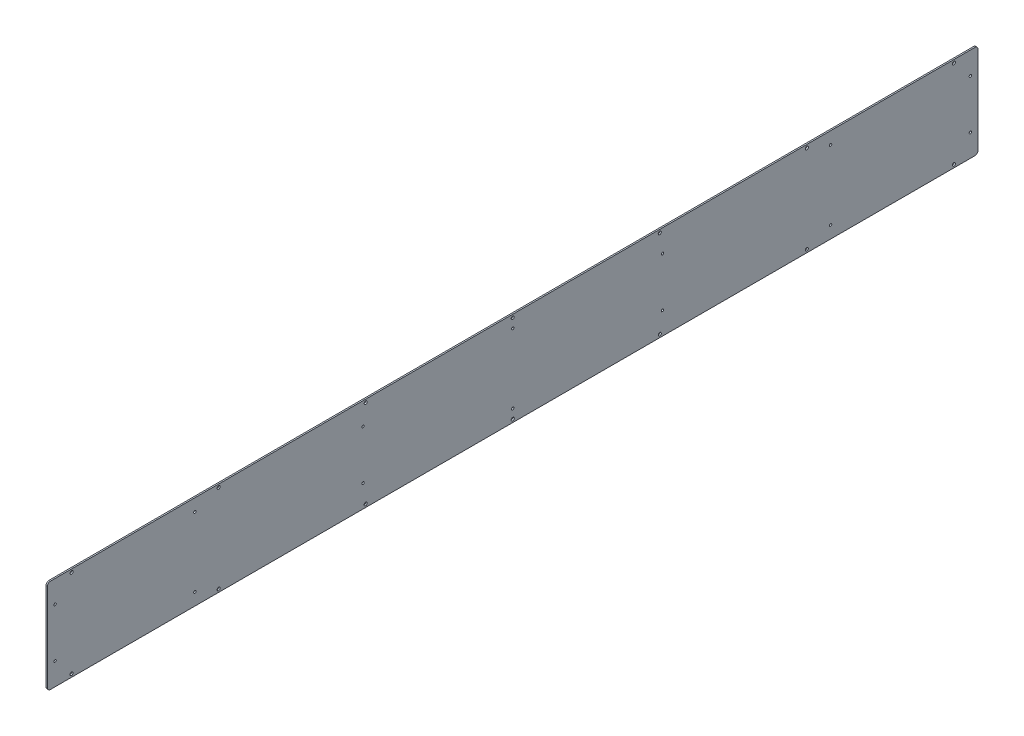
from build123d import *

# Parameters (mm, degrees)
SKETCH1_W                   = 1928.8125
SKETCH1_H                   = 194.564
BOSS_EXTRUDE1_DEPTH         = 2.9972
SKETCH2_R                   = 2.4511
CUT_EXTRUDE1_DEPTH          = 3.9972
FILLET1_R                   = 6.35
F_1_4_0_25_DIAMETER_HOLE1_D = 6.35


with BuildPart() as part:
    # Sketch1 → Boss-Extrude1 (new body)
    with BuildSketch(Plane(origin=(0, 0, 0), x_dir=(0, 0, -1), z_dir=(1, 0, 0))):
        with Locations((964.40625, 97.282)):
            Rectangle(SKETCH1_W, SKETCH1_H)
    extrude(amount=BOSS_EXTRUDE1_DEPTH)

    # Sketch2 → Cut-Extrude1 (cut, through all)
    with BuildSketch(Plane(origin=(2.9972, 0, 0), x_dir=(0, 0, -1), z_dir=(1, 0, 0))):
        with Locations((15.875, 148.082)):
            Circle(SKETCH2_R)
        with Locations((654.05, 148.082)):
            Circle(SKETCH2_R)
        with Locations((305.562, 169.164)):
            Circle(SKETCH2_R)
        with Locations((964.40625, 169.164)):
            Circle(SKETCH2_R)
        with Locations((964.40625, 25.4)):
            Circle(SKETCH2_R)
        with Locations((305.562, 25.4)):
            Circle(SKETCH2_R)
        with Locations((15.875, 46.482)):
            Circle(SKETCH2_R)
        with Locations((654.05, 46.482)):
            Circle(SKETCH2_R)
        with Locations((1623.2505, 25.4)):
            Circle(SKETCH2_R)
        with Locations((1623.2505, 169.164)):
            Circle(SKETCH2_R)
        with Locations((1912.9375, 46.482)):
            Circle(SKETCH2_R)
        with Locations((1912.9375, 148.082)):
            Circle(SKETCH2_R)
        with Locations((1274.7625, 46.482)):
            Circle(SKETCH2_R)
        with Locations((1274.7625, 148.082)):
            Circle(SKETCH2_R)
    extrude(amount=-CUT_EXTRUDE1_DEPTH, mode=Mode.SUBTRACT)

    # Fillet1
    fillet1_edges = [part.edges().sort_by_distance(p)[0] for p in [
        (1.4986, 194.564, 0),
        (1.4986, 194.564, -1928.8125),
        (1.4986, 0, -1928.8125),
        (1.4986, 0, 0),
    ]]
    fillet(fillet1_edges, radius=FILLET1_R)

    # 1/4 (0.25) Diameter Hole1 (through all)
    with Locations(Plane(origin=(2.9972, 0, 0), x_dir=(0, 0, -1), z_dir=(1, 0, 0))):
        with Locations((964.40625, 6.35), (659.60625, 6.35), (354.80625, 6.35), (50.00625, 6.35), (1269.20625, 6.35), (1574.00625, 6.35), (1878.80625, 6.35), (1878.80625, 188.214), (1574.00625, 188.214), (1269.20625, 188.214), (50.00625, 188.214), (354.80625, 188.214), (659.60625, 188.214), (964.40625, 188.214)):
            Hole(F_1_4_0_25_DIAMETER_HOLE1_D / 2)


solid = part.part
